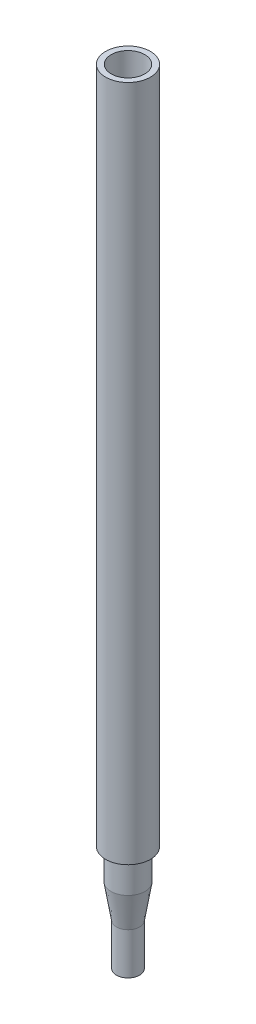
from build123d import *


with BuildPart() as part:
    # Sketch1 → Revolve1 (revolve)
    with BuildSketch(Plane(origin=(0, 0, 0), x_dir=(0, 0, -1), z_dir=(1, 0, 0))):
        Polygon((-1.555, 0), (-1.555, 5.6), (-2.29, 10.102852648), (-2.29, 13.672852648), (-3, 14.17), (-3, 105), (-2.25, 105), (-2.25, 14.560425288), (-1.54, 14.063277936), (-1.54, 10.16366146), (-0.805, 5.660808812), (-0.805, 0), align=None)
    revolve(axis=Axis((0, 0, 0), (0, 1, 0)))


solid = part.part
